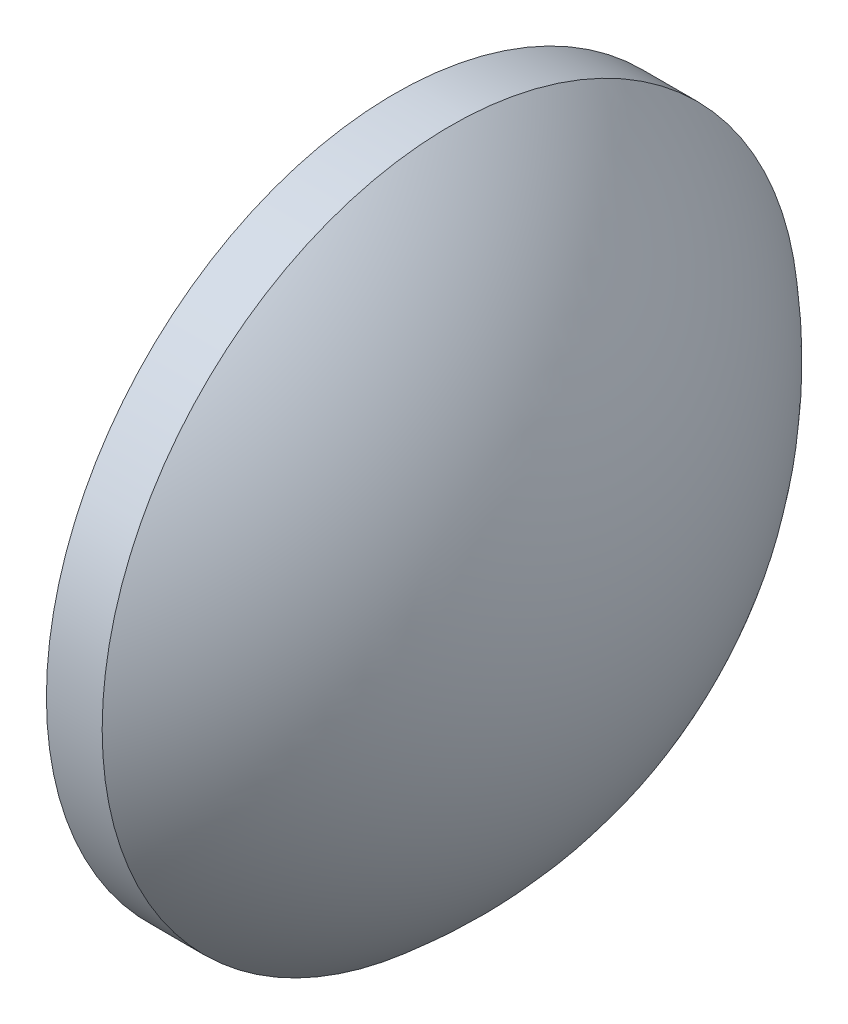
from build123d import *


with BuildPart() as part:
    # 草图1 → 旋转1 (revolve)
    with BuildSketch(Plane.XY, mode=Mode.PRIVATE) as revolve_1_sk:
        with BuildLine():
            Line((409.308292932, -5.229201433), (409.308292932, 7.270798567))
            Line((409.308292932, 7.270798567), (411.308292932, 7.270798567))
            ThreePointArc((411.308292932, 7.270798567), (415.630591594, 1.67350818), (417.168292932, -5.229201433))
            Line((417.168292932, -5.229201433), (409.308292932, -5.229201433))
        make_face()
    revolve(revolve_1_sk.sketch.rotate(Axis((407.279185353, -5.229201433, 0), (1, 0, 0)), 180), axis=Axis((407.279185353, -5.229201433, 0), (1, 0, 0)))  # turned: the seam where the file's is


solid = part.part
